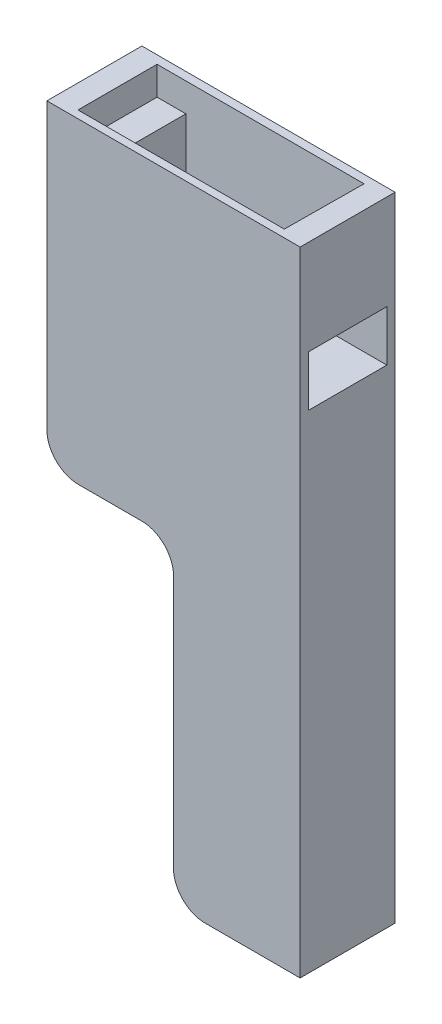
from build123d import *

# Parameters (mm, degrees)
SKETCH_1_W          = 40
SKETCH_1_H          = 15
EXTRUDE_1_DEPTH     = 50
SKETCH_2_W          = 20
SKETCH_2_H          = 50
CUT_EXTRUDE_1_DEPTH = 16
FILLET_2_R          = 5
FILLET_3_R          = 5
CUT_EXTRUDE_2_DEPTH = 4.5
SKETCH_5_W          = 23.5
SKETCH_5_H          = 12.4
CUT_EXTRUDE_3_DEPTH = 18.5
SKETCH_7_W          = 12.4
SKETCH_7_H          = 8
CUT_EXTRUDE_4_DEPTH = 9.25
CUT_EXTRUDE_7_DEPTH = 12


with BuildPart() as part:
    # 스케치1 → 보스-돌출1 (new body, symmetric)
    with BuildSketch(Plane(origin=(0, 0, 0), x_dir=(1, 0, 0), z_dir=(0, 1, 0))):
        Rectangle(SKETCH_1_W, SKETCH_1_H)
    extrude(amount=EXTRUDE_1_DEPTH, both=True)

    # 스케치2 → 컷-돌출1 (cut, through all)
    with BuildSketch(Plane.XY.offset(7.5)):
        with Locations((-10, -25)):
            Rectangle(SKETCH_2_W, SKETCH_2_H)
    extrude(amount=-CUT_EXTRUDE_1_DEPTH, mode=Mode.SUBTRACT)

    # 필렛2
    fillet_2_edges = [part.edges().sort_by_distance(p)[0] for p in [
        (-20, 0, 0),
        (0, 0, 0),
    ]]
    fillet(fillet_2_edges, radius=FILLET_2_R)

    # 필렛3
    fillet_3_edges = [part.edges().sort_by_distance(p)[0] for p in [
        (0, -50, 0),
    ]]
    fillet(fillet_3_edges, radius=FILLET_3_R)

    # 스케치4 → 컷-돌출2 (cut)
    with BuildSketch(Plane(origin=(0, 50, 0), x_dir=(1, 0, 0), z_dir=(0, 1, 0))):
        Polygon((16.4, 6.2), (-16.3, 6.2), (-16.3, -6.3), (16.3, -6.3), align=None)
    extrude(amount=-CUT_EXTRUDE_2_DEPTH, mode=Mode.SUBTRACT)

    # 스케치5 → 컷-돌출3 (cut)
    with BuildSketch(Plane(origin=(0, 45.5, 0), x_dir=(1, 0, 0), z_dir=(0, 1, 0))):
        Rectangle(SKETCH_5_W, SKETCH_5_H)
    extrude(amount=-CUT_EXTRUDE_3_DEPTH, mode=Mode.SUBTRACT)

    # 스케치7 → 컷-돌출4 (cut, through all)
    with BuildSketch(Plane.ZY.offset(-11.75)):
        with Locations((0, 31)):
            Rectangle(SKETCH_7_W, SKETCH_7_H)
    extrude(amount=-CUT_EXTRUDE_4_DEPTH, mode=Mode.SUBTRACT)

    # 스케치10 → 컷-돌출7 (cut)
    with BuildSketch(Plane(origin=(0, 45.5, 0), x_dir=(1, 0, 0), z_dir=(0, 1, 0))):
        Polygon((13.75, -6.3), (13.75, 6.2), (11.75, 6.2), (11.75, -6.2), (11.75, -6.3), align=None)
    extrude(amount=-CUT_EXTRUDE_7_DEPTH, mode=Mode.SUBTRACT)


solid = part.part
